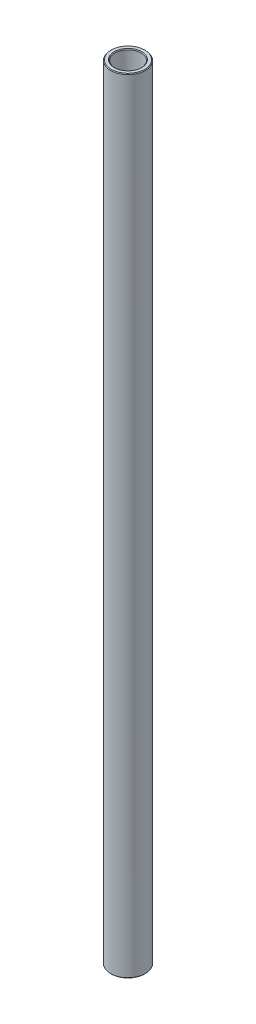
from build123d import *

# Parameters (mm, degrees)
SKETCH1_W     = 1.5875
SKETCH1_H     = 285.75
CHAMFER1_SIZE = 0.254


with BuildPart() as part:
    # Sketch1 → Revolve1 (revolve)
    with BuildSketch(Plane.XY):
        with Locations((5.55625, 0)):
            Rectangle(SKETCH1_W, SKETCH1_H)
    revolve(axis=Axis((0, 11.60859375, 0), (0, -1, 0)))

    # Chamfer1
    chamfer1_edges = [part.edges().sort_by_distance(p)[0] for p in [
        (-4.7625, -142.875, 0),
        (-6.35, -142.875, 0),
        (-6.35, 142.875, 0),
        (-4.7625, 142.875, 0),
    ]]
    chamfer(chamfer1_edges, length=CHAMFER1_SIZE)


solid = part.part
